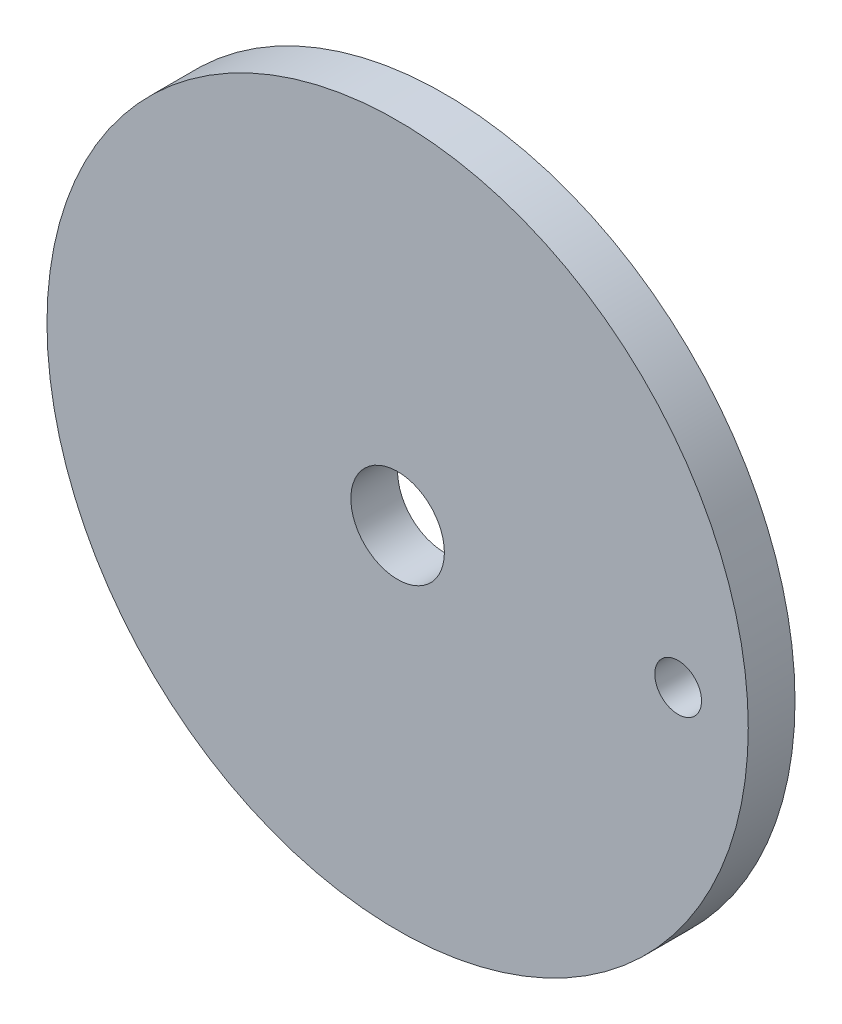
from build123d import *

# Parameters (mm, degrees)
SKETCH1_R           = 1
BOSS_EXTRUDE1_DEPTH = 15
SKETCH2_R           = 7.5
BOSS_EXTRUDE2_DEPTH = 1
SKETCH3_R           = 0.5
CUT_EXTRUDE1_DEPTH  = 10
SKETCH5_R           = 1
CUT_EXTRUDE2_DEPTH  = 20


with BuildPart() as part:
    # Sketch1 → Boss-Extrude1 (new body)
    with BuildSketch(Plane.XY):
        Circle(SKETCH1_R)
    extrude(amount=BOSS_EXTRUDE1_DEPTH)

    # Sketch2 → Boss-Extrude2 (add)
    with BuildSketch(Plane.XY.offset(15)):
        Circle(SKETCH2_R)
    extrude(amount=BOSS_EXTRUDE2_DEPTH)

    # Sketch3 → Cut-Extrude1 (cut)
    with BuildSketch(Plane.XY.offset(16)):
        with Locations((6, 0)):
            Circle(SKETCH3_R)
    extrude(amount=-CUT_EXTRUDE1_DEPTH, mode=Mode.SUBTRACT)

    # Sketch5 → Cut-Extrude2 (cut)
    with BuildSketch(Plane.XY.offset(16)):
        Circle(SKETCH5_R)
    extrude(amount=-CUT_EXTRUDE2_DEPTH, mode=Mode.SUBTRACT)


solid = part.part
